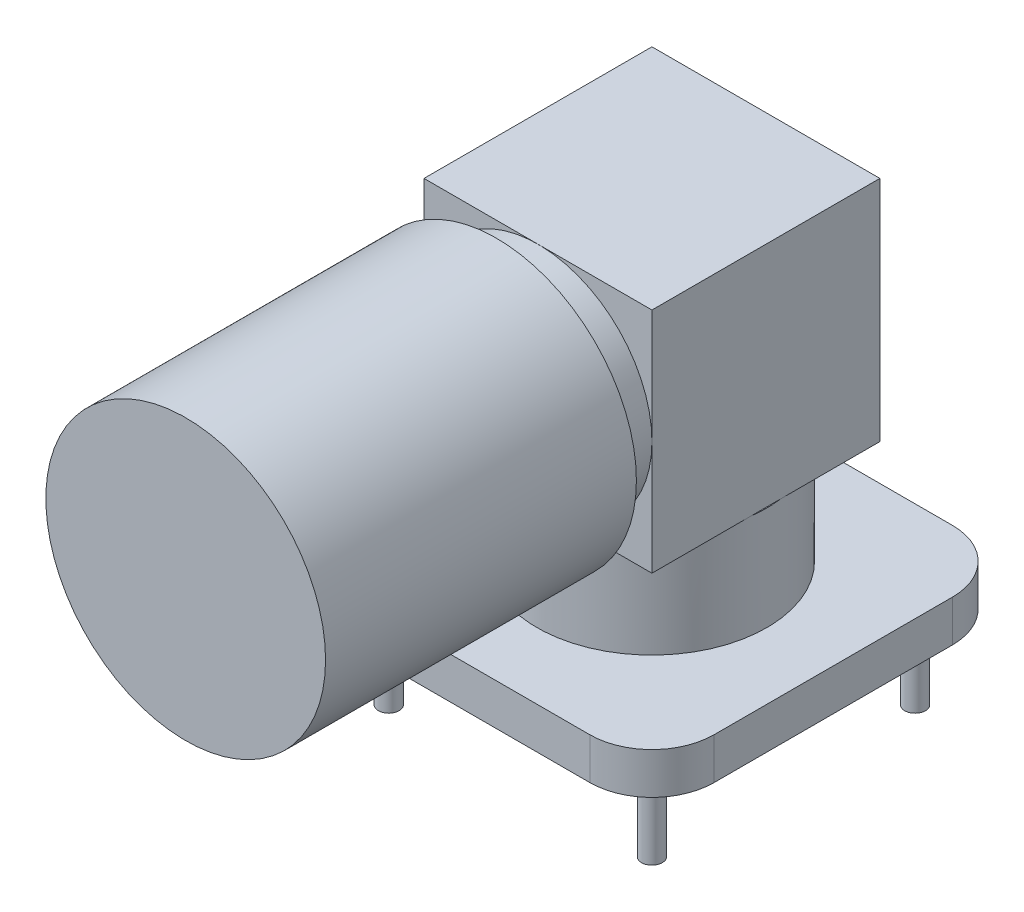
from build123d import *

# Parameters (mm, degrees)
AUFSATZ_LINEAR_AUSTRAGEN1_DEPTH = 2
SKIZZE2_R                       = 0.5
AUFSATZ_LINEAR_AUSTRAGEN2_DEPTH = 4
SKIZZE3_R                       = 5.55
AUFSATZ_LINEAR_AUSTRAGEN3_DEPTH = 5
SKIZZE4_W                       = 11
SKIZZE4_H                       = 11
AUFSATZ_LINEAR_AUSTRAGEN4_DEPTH = 11
SKIZZE5_R                       = 5.5
AUFSATZ_LINEAR_AUSTRAGEN6_DEPTH = 10
AUFSATZ_LINEAR_START            = 2
SKIZZE6_R                       = 6.75
AUFSATZ_LINEAR_AUSTRAGEN7_DEPTH = 15


with BuildPart() as part:
    # Skizze1 → Aufsatz-Linear austragen1 (new body)
    with BuildSketch(Plane(origin=(0, 0, 0), x_dir=(1, 0, 0), z_dir=(0, 1, 0))):
        with BuildLine():
            Line((-5.75, -8.75), (5.75, -8.75))
            ThreePointArc((5.75, -8.75), (7.871320344, -7.871320344), (8.75, -5.75))
            Line((8.75, -5.75), (8.75, 5.75))
            ThreePointArc((8.75, 5.75), (7.871320344, 7.871320344), (5.75, 8.75))
            Line((5.75, 8.75), (-5.75, 8.75))
            ThreePointArc((-5.75, 8.75), (-7.871320344, 7.871320344), (-8.75, 5.75))
            Line((-8.75, 5.75), (-8.75, -5.75))
            ThreePointArc((-8.75, -5.75), (-7.871320344, -7.871320344), (-5.75, -8.75))
        make_face()
    extrude(amount=AUFSATZ_LINEAR_AUSTRAGEN1_DEPTH)

    # Skizze2 → Aufsatz-Linear austragen2 (add)
    with BuildSketch(Plane.XZ):
        with Locations((6.35, -6.35)):
            Circle(SKIZZE2_R)
        with Locations((-6.35, 6.35)):
            Circle(SKIZZE2_R)
        with Locations((6.35, 6.35)):
            Circle(SKIZZE2_R)
        with Locations((-6.35, -6.35)):
            Circle(SKIZZE2_R)
        Circle(SKIZZE2_R)
    extrude(amount=AUFSATZ_LINEAR_AUSTRAGEN2_DEPTH)

    # Skizze3 → Aufsatz-Linear austragen3 (add)
    with BuildSketch(Plane(origin=(0, 2, 0), x_dir=(1, 0, 0), z_dir=(0, 1, 0))):
        Circle(SKIZZE3_R)
    extrude(amount=AUFSATZ_LINEAR_AUSTRAGEN3_DEPTH)

    # Skizze4 → Aufsatz-Linear austragen4 (add)
    with BuildSketch(Plane(origin=(0, 7, 0), x_dir=(1, 0, 0), z_dir=(0, 1, 0))):
        Rectangle(SKIZZE4_W, SKIZZE4_H)
    extrude(amount=AUFSATZ_LINEAR_AUSTRAGEN4_DEPTH)


with BuildPart() as body_2:
    # Skizze5 → Aufsatz-Linear austragen6 (new body)
    with BuildSketch(Plane.XY.offset(5.5)):
        with Locations((0, 12.5)):
            Circle(SKIZZE5_R)
    extrude(amount=AUFSATZ_LINEAR_AUSTRAGEN6_DEPTH)


with BuildPart() as body_3:
    # Skizze6 → Aufsatz-Linear austragen7 (new body)
    with BuildSketch(Plane.XY.offset(5.5).offset(AUFSATZ_LINEAR_START)):
        with Locations((0, 12.5)):
            Circle(SKIZZE6_R)
    extrude(amount=AUFSATZ_LINEAR_AUSTRAGEN7_DEPTH)


solid = Compound([part.part, body_2.part, body_3.part])
